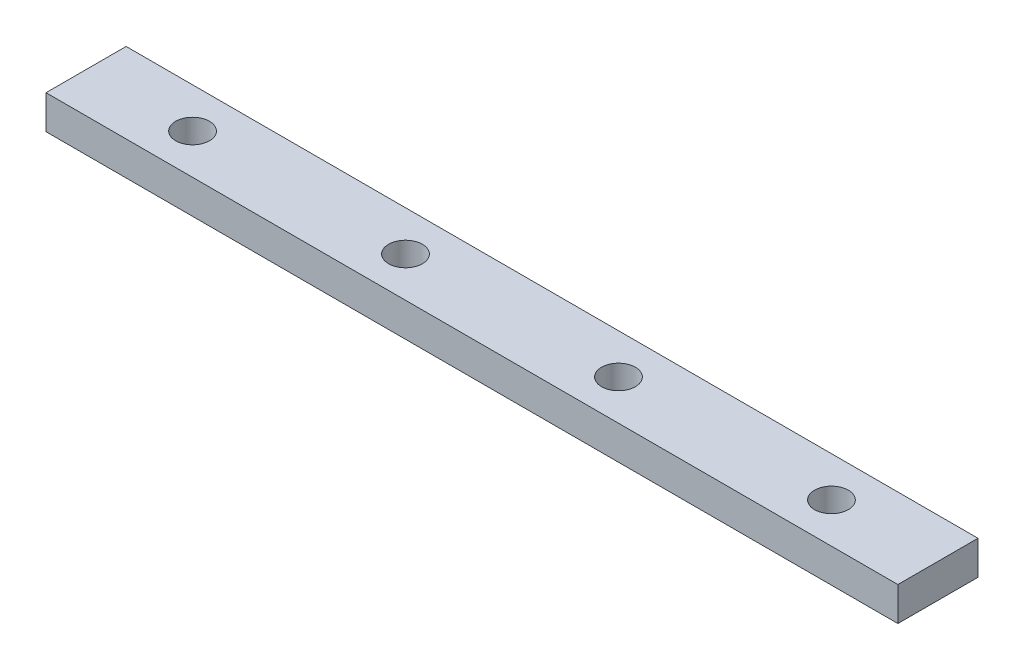
from build123d import *

# Parameters (mm, degrees)
SKETCH1_W           = 30.1
SKETCH1_H           = 12.7
BOSS_EXTRUDE1_DEPTH = 320
SKETCH3_R           = 6.35
CUT_EXTRUDE1_DEPTH  = 13.7


with BuildPart() as part:
    # Sketch1 → Boss-Extrude1 (new body)
    with BuildSketch(Plane(origin=(0, 0, 0), x_dir=(0, 0, -1), z_dir=(1, 0, 0))):
        with Locations((15.05, 6.35)):
            Rectangle(SKETCH1_W, SKETCH1_H)
    extrude(amount=BOSS_EXTRUDE1_DEPTH)

    # Sketch3 → Cut-Extrude1 (cut, through all)
    with BuildSketch(Plane(origin=(0, 12.7, 0), x_dir=(1, 0, 0), z_dir=(0, 1, 0))):
        with Locations((120, 15.05)):
            Circle(SKETCH3_R)
        with Locations((200, 15.05)):
            Circle(SKETCH3_R)
        with Locations((280, 15.05)):
            Circle(SKETCH3_R)
        with Locations((40, 15.05)):
            Circle(SKETCH3_R)
    extrude(amount=-CUT_EXTRUDE1_DEPTH, mode=Mode.SUBTRACT)


solid = part.part
